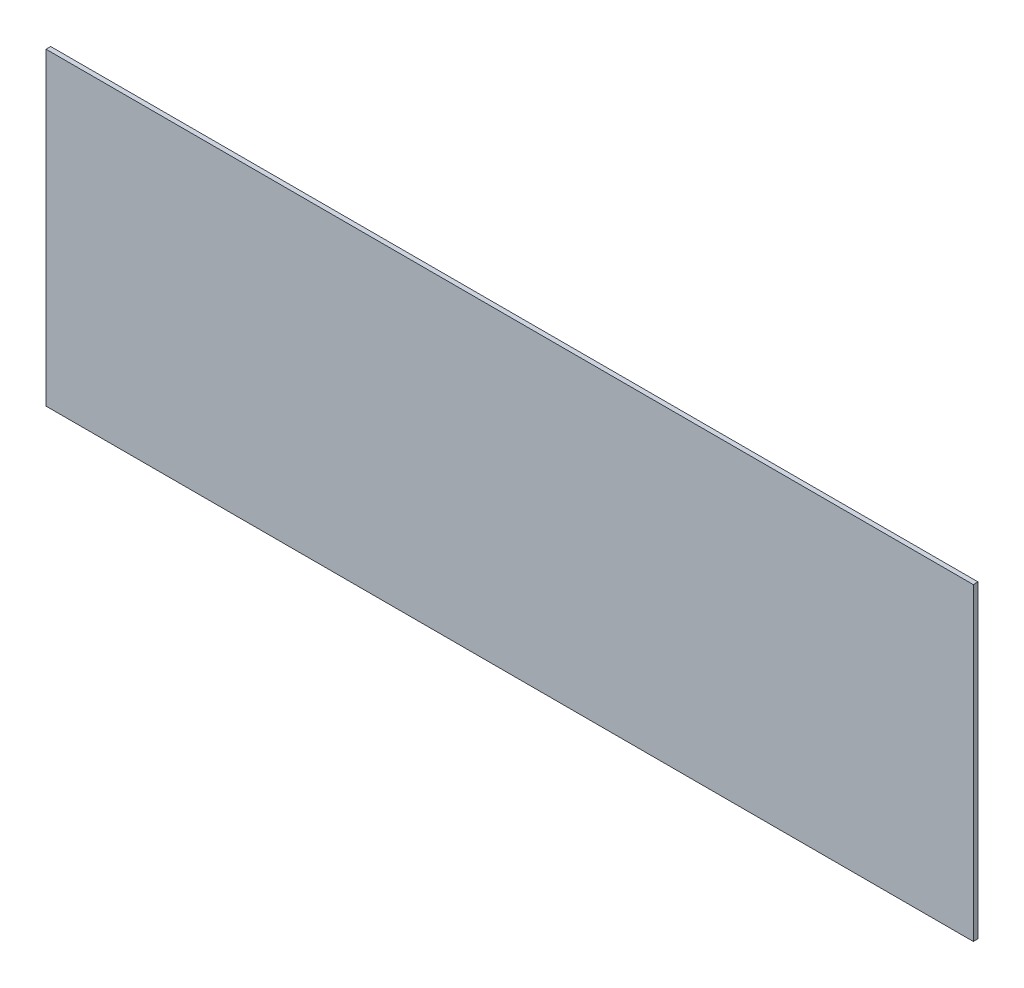
from build123d import *

# Parameters (mm, degrees)
SKETCH1_W           = 1257.299997698
SKETCH1_H           = 419.099994545
BOSS_EXTRUDE1_DEPTH = 6.35


with BuildPart() as part:
    # Sketch1 → Boss-Extrude1 (new body)
    with BuildSketch(Plane(origin=(0, 0, 230.348189396), x_dir=(-1, 0, 0), z_dir=(0, 0, -1))):
        with Locations((-1622.689797302, 260.973408393)):
            Rectangle(SKETCH1_W, SKETCH1_H)
    extrude(amount=BOSS_EXTRUDE1_DEPTH)


solid = part.part
